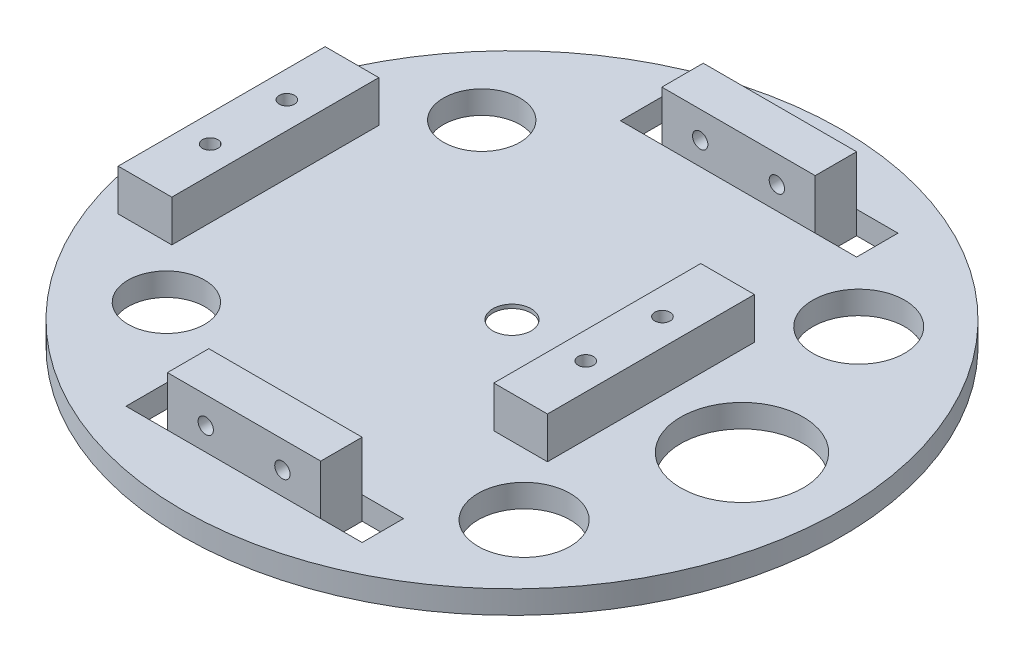
from build123d import *

# Parameters (mm, degrees)
CROQUIS1_R              = 42.989543869
CROQUIS1_R_2            = 8.000000719
CROQUIS1_R_3            = 6.000000354
CROQUIS1_R_4            = 4.999998849
CROQUIS1_R_5            = 5.000081965
CROQUIS1_R_6            = 6.000000031
CROQUIS1_W              = 5.400000572
CROQUIS1_H              = 5.400000573
CROQUIS1_W_2            = 5.400001526
CROQUIS1_H_2            = 5.400001526
CROQUIS1_W_3            = 5.400001525
SALIENTE_EXTRUIR1_DEPTH = 2.5
CROQUIS2_R              = 42.989543869
CROQUIS2_R_2            = 5.000081965
CROQUIS2_R_3            = 6.000000031
CROQUIS2_R_4            = 8.000000719
CROQUIS2_R_5            = 6.000000354
CROQUIS2_R_6            = 4.999998849
CROQUIS2_R_7            = 2.5
CROQUIS2_W              = 5.400000572
CROQUIS2_H              = 5.400000573
CROQUIS2_W_2            = 5.400001525
CROQUIS2_H_2            = 5.400001526
CROQUIS2_W_3            = 5.400001526
SALIENTE_EXTRUIR2_DEPTH = 0.5
CROQUIS3_W              = 19.999999047
CROQUIS3_H              = 5.400000573
CROQUIS3_W_2            = 19.999998093
CROQUIS3_H_2            = 5.400001526
SALIENTE_EXTRUIR3_DEPTH = 6.5
CROQUIS4_R              = 1
CORTAR_EXTRUIR1_DEPTH   = 94.5
CROQUIS5_W              = 7.000000953
CROQUIS5_H              = 27
CROQUIS5_R              = 1.000001566
CROQUIS5_W_2            = 7.000000954
SALIENTE_EXTRUIR4_DEPTH = 5.4


with BuildPart() as part:
    # Croquis1 → Saliente-Extruir1 (new body)
    with BuildSketch(Plane(origin=(0, 0, 0), x_dir=(1, 0, 0), z_dir=(0, 1, 0))):
        with Locations((0.133743246, 0.231297164)):
            Circle(CROQUIS1_R)
        with Locations((30.123277351, 0.24111594)):
            Circle(CROQUIS1_R_2, mode=Mode.SUBTRACT)
        with Locations((23.52660556, 22.065066477)):
            Circle(CROQUIS1_R_3, mode=Mode.SUBTRACT)
        with Locations((-24.390140184, 20.810319956)):
            Circle(CROQUIS1_R_4, mode=Mode.SUBTRACT)
        with Locations((-24.392687184, -20.328024023)):
            Circle(CROQUIS1_R_5, mode=Mode.SUBTRACT)
        with Locations((23.526602762, -21.582829156)):
            Circle(CROQUIS1_R_6, mode=Mode.SUBTRACT)
        with BuildLine():
            Line((4.854387983, 7.302748706), (11.022837385, 9.362418202))
            ThreePointArc((11.022837385, 9.362418202), (13.987829641, 8.239301442), (13.466977705, 5.11179707))
            Line((13.466977705, 5.11179707), (8.599027265, 0.799598431))
            ThreePointArc((8.599027265, 0.799598431), (8.617971382, 0.221716337), (8.597699336, -0.356120697))
            Line((8.597699336, -0.356120697), (13.465650144, -4.668319833))
            ThreePointArc((13.465650144, -4.668319833), (13.975498626, -7.797636828), (11.006574422, -8.910318006))
            Line((11.006574422, -8.910318006), (4.838125635, -6.850648581))
            ThreePointArc((4.838125635, -6.850648581), (4.347137119, -7.155995714), (3.836579545, -7.427358125))
            Line((3.836579545, -7.427358125), (2.536080952, -13.799226756))
            ThreePointArc((2.536080952, -13.799226756), (0.080937178, -15.805426992), (-2.36713509, -13.790603798))
            Line((-2.36713509, -13.790603798), (-3.667633438, -7.418735734))
            ThreePointArc((-3.667633438, -7.418735734), (-4.177566071, -7.146200773), (-4.667851599, -6.839726149))
            Line((-4.667851599, -6.839726149), (-10.836301, -8.899395645))
            ThreePointArc((-10.836301, -8.899395645), (-13.801293256, -7.776278885), (-13.28044132, -4.648774514))
            Line((-13.28044132, -4.648774514), (-8.41249088, -0.336575875))
            ThreePointArc((-8.41249088, -0.336575875), (-8.431434998, 0.24130622), (-8.411162951, 0.819143254))
            Line((-8.411162951, 0.819143254), (-13.279113759, 5.131342389))
            ThreePointArc((-13.279113759, 5.131342389), (-13.788962242, 8.260659385), (-10.820038037, 9.373340563))
            Line((-10.820038037, 9.373340563), (-4.65158925, 7.313671137))
            ThreePointArc((-4.65158925, 7.313671137), (-4.160600735, 7.619018271), (-3.65004316, 7.890380681))
            Line((-3.65004316, 7.890380681), (-2.349544567, 14.262249313))
            ThreePointArc((-2.349544567, 14.262249313), (0.105599207, 16.268449549), (2.553671475, 14.253626355))
            Line((2.553671475, 14.253626355), (3.854169823, 7.88175829))
            ThreePointArc((3.854169823, 7.88175829), (4.364102455, 7.60922333), (4.854387983, 7.302748706))
        make_face(mode=Mode.SUBTRACT)
        with Locations((-12.576717154, -32.008881065)):
            Rectangle(CROQUIS1_W, CROQUIS1_H, mode=Mode.SUBTRACT)
        with Locations((12.823282465, -32.008881065)):
            Rectangle(CROQUIS1_W, CROQUIS1_H, mode=Mode.SUBTRACT)
        with Locations((-12.576716677, 32.491118458)):
            Rectangle(CROQUIS1_W_2, CROQUIS1_H_2, mode=Mode.SUBTRACT)
        with Locations((12.823282942, 32.491118458)):
            Rectangle(CROQUIS1_W_3, CROQUIS1_H_2, mode=Mode.SUBTRACT)
    extrude(amount=SALIENTE_EXTRUIR1_DEPTH)

    # Croquis2 → Saliente-Extruir2 (add)
    with BuildSketch(Plane(origin=(0, 2.5, 0), x_dir=(1, 0, 0), z_dir=(0, 1, 0))):
        with Locations((0.133743246, 0.231297164)):
            Circle(CROQUIS2_R)
        with Locations((-24.392687184, -20.328024023)):
            Circle(CROQUIS2_R_2, mode=Mode.SUBTRACT)
        with Locations((23.526602762, -21.582829156)):
            Circle(CROQUIS2_R_3, mode=Mode.SUBTRACT)
        with Locations((30.123277351, 0.24111594)):
            Circle(CROQUIS2_R_4, mode=Mode.SUBTRACT)
        with Locations((23.52660556, 22.065066477)):
            Circle(CROQUIS2_R_5, mode=Mode.SUBTRACT)
        with Locations((-24.390140184, 20.810319956)):
            Circle(CROQUIS2_R_6, mode=Mode.SUBTRACT)
        with Locations((0.133743246, 0.231297164)):
            Circle(CROQUIS2_R_7, mode=Mode.SUBTRACT)
        with Locations((-12.576717154, -32.008881065)):
            Rectangle(CROQUIS2_W, CROQUIS2_H, mode=Mode.SUBTRACT)
        with Locations((12.823282465, -32.008881065)):
            Rectangle(CROQUIS2_W, CROQUIS2_H, mode=Mode.SUBTRACT)
        with Locations((12.823282942, 32.491118458)):
            Rectangle(CROQUIS2_W_2, CROQUIS2_H_2, mode=Mode.SUBTRACT)
        with Locations((-12.576716677, 32.491118458)):
            Rectangle(CROQUIS2_W_3, CROQUIS2_H_2, mode=Mode.SUBTRACT)
    extrude(amount=SALIENTE_EXTRUIR2_DEPTH)

    # Croquis3 → Saliente-Extruir3 (add)
    with BuildSketch(Plane(origin=(0, 3, 0), x_dir=(1, 0, 0), z_dir=(0, 1, 0))):
        with Locations((0.123282655, -32.008881065)):
            Rectangle(CROQUIS3_W, CROQUIS3_H)
        with Locations((0.123283133, 32.491118458)):
            Rectangle(CROQUIS3_W_2, CROQUIS3_H_2)
    extrude(amount=SALIENTE_EXTRUIR3_DEPTH)

    # Croquis4 → Cortar-Extruir1 (cut)
    with BuildSketch(Plane.XY.offset(34.708881352)):
        with Locations((-4.876716868, 6)):
            Circle(CROQUIS4_R)
        with Locations((5.123283132, 6)):
            Circle(CROQUIS4_R)
    extrude(amount=-CORTAR_EXTRUIR1_DEPTH, mode=Mode.SUBTRACT)

    # Croquis5 → Saliente-Extruir4 (add)
    with BuildSketch(Plane(origin=(0, 3, 0), x_dir=(1, 0, 0), z_dir=(0, 1, 0))):
        with Locations((-34.010001431, 0)):
            Rectangle(CROQUIS5_W, CROQUIS5_H)
        with Locations((-34.010010931, 4.999991869)):
            Circle(CROQUIS5_R, mode=Mode.SUBTRACT)
        with Locations((-34.010010931, -4.999998876)):
            Circle(CROQUIS5_R, mode=Mode.SUBTRACT)
        with Locations((14.990000477, 0)):
            Rectangle(CROQUIS5_W_2, CROQUIS5_H)
        with Locations((14.989999497, 4.999991869)):
            Circle(CROQUIS5_R, mode=Mode.SUBTRACT)
        with Locations((14.989999497, -4.999998876)):
            Circle(CROQUIS5_R, mode=Mode.SUBTRACT)
    extrude(amount=SALIENTE_EXTRUIR4_DEPTH)


solid = part.part
